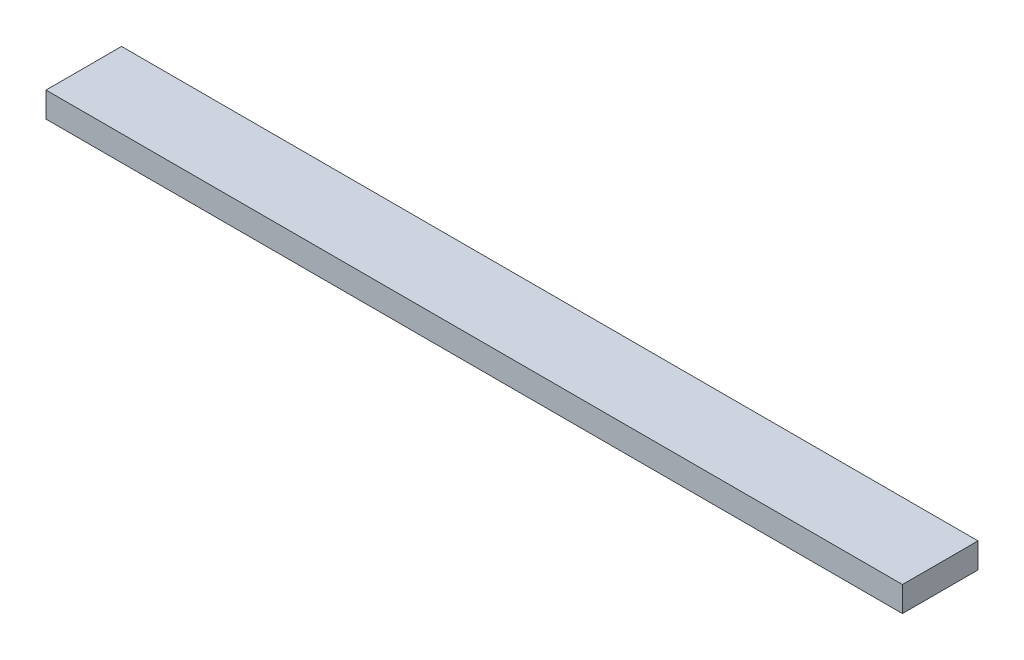
from build123d import *

# Parameters (mm, degrees)
CROQUIS1_W              = 170
CROQUIS1_H              = 15
SALIENTE_EXTRUIR1_DEPTH = 5


with BuildPart() as part:
    # Croquis1 → Saliente-Extruir1 (new body)
    with BuildSketch(Plane(origin=(0, 0, 0), x_dir=(1, 0, 0), z_dir=(0, 1, 0))):
        with Locations((85, 7.5)):
            Rectangle(CROQUIS1_W, CROQUIS1_H)
    extrude(amount=SALIENTE_EXTRUIR1_DEPTH)


solid = part.part
